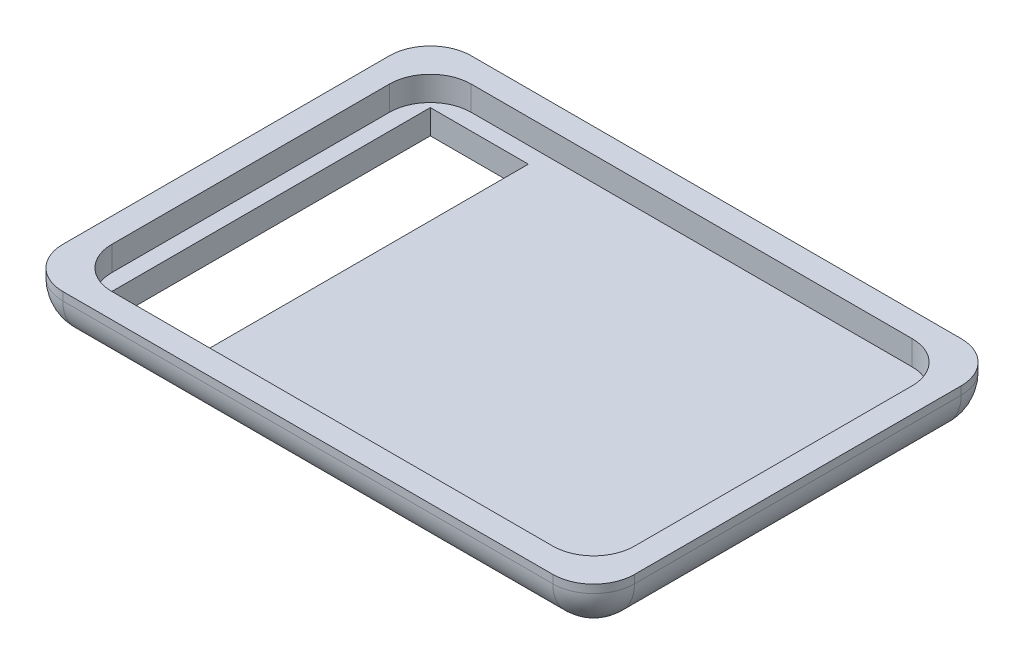
from build123d import *

# Parameters (mm, degrees)
SKETCH1_W               = 70
SKETCH1_H               = 50
BOSS_EXTRUDE1_DEPTH     = 6
SHELL1_T                = -3
FILLET1_R               = 5
FILLET2_R               = 5
FILLET3_R               = 5
FILLET4_R               = 5
FILLET5_R               = 5
FILLET6_R               = 5
FILLET7_R               = 5
FILLET8_R               = 5
FILLET9_R               = 5
CUT_EXTRUDE1_DEPTH      = 10
CUT_EXTRUDE1_DEPTH_BACK = 10
SKETCH2_W               = 12
SKETCH2_H               = 40


with BuildPart() as part:
    # Sketch1 → Boss-Extrude1 (new body)
    with BuildSketch(Plane(origin=(0, 0, 0), x_dir=(1, 0, 0), z_dir=(0, 1, 0))):
        Rectangle(SKETCH1_W, SKETCH1_H)
    extrude(amount=BOSS_EXTRUDE1_DEPTH)

    # Shell1
    shell1_openings = [part.faces().sort_by_distance(p)[0] for p in [
        (0, 6, 0),
    ]]
    offset(amount=SHELL1_T, openings=shell1_openings, kind=Kind.INTERSECTION)

    # Fillet1
    fillet1_edges = [part.edges().sort_by_distance(p)[0] for p in [
        (35, 3, 25),
    ]]
    fillet(fillet1_edges, radius=FILLET1_R)

    # Fillet2
    fillet2_edges = [part.edges().sort_by_distance(p)[0] for p in [
        (35, 3, -25),
    ]]
    fillet(fillet2_edges, radius=FILLET2_R)

    # Fillet3
    fillet3_edges = [part.edges().sort_by_distance(p)[0] for p in [
        (-35, 3, 25),
    ]]
    fillet(fillet3_edges, radius=FILLET3_R)

    # Fillet4
    fillet4_edges = [part.edges().sort_by_distance(p)[0] for p in [
        (-35, 3, -25),
    ]]
    fillet(fillet4_edges, radius=FILLET4_R)

    # Fillet5
    fillet5_edges = [part.edges().sort_by_distance(p)[0] for p in [
        (-33.535533906, 0, -23.535533906),
        (-33.535533906, 0, 23.535533906),
        (33.535533906, 0, -23.535533906),
        (33.535533906, 0, 23.535533906),
        (35, 0, 0),
        (0, 0, -25),
        (-35, 0, 0),
        (0, 0, 25),
    ]]
    fillet(fillet5_edges, radius=FILLET5_R)

    # Fillet6
    fillet6_edges = [part.edges().sort_by_distance(p)[0] for p in [
        (32, 4.5, 22),
    ]]
    fillet(fillet6_edges, radius=FILLET6_R)

    # Fillet7
    fillet7_edges = [part.edges().sort_by_distance(p)[0] for p in [
        (-32, 4.5, 22),
    ]]
    fillet(fillet7_edges, radius=FILLET7_R)

    # Fillet8
    fillet8_edges = [part.edges().sort_by_distance(p)[0] for p in [
        (-32, 4.5, -22),
    ]]
    fillet(fillet8_edges, radius=FILLET8_R)

    # Fillet9
    fillet9_edges = [part.edges().sort_by_distance(p)[0] for p in [
        (32, 4.5, -22),
    ]]
    fillet(fillet9_edges, radius=FILLET9_R)

    # Sketch2 → Cut-Extrude1 (cut, two sides: drawn at the far end of the back side and taken through both)
    with BuildSketch(Plane.XZ.offset(-CUT_EXTRUDE1_DEPTH_BACK)):
        with Locations((-24, 0)):
            Rectangle(SKETCH2_W, SKETCH2_H)
    extrude(amount=CUT_EXTRUDE1_DEPTH + CUT_EXTRUDE1_DEPTH_BACK, mode=Mode.SUBTRACT)


solid = part.part
